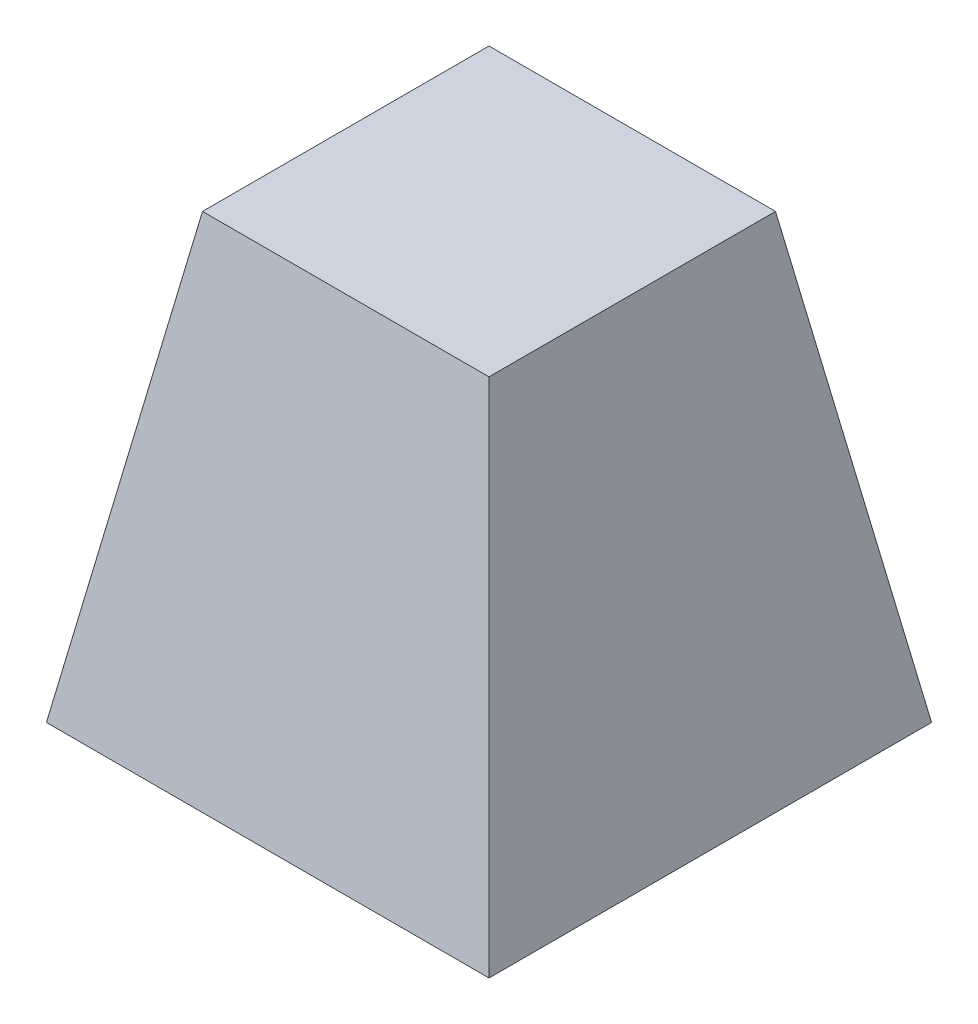
from build123d import *

# Parameters (mm, degrees)
SKETCH1_W           = 25.4
SKETCH1_H           = 25.4
BOSS_EXTRUDE1_DEPTH = 25.4
BOSS_EXTRUDE1_TAPER = 10


with BuildPart() as part:
    # Sketch1 → Boss-Extrude1 (new body)
    with BuildSketch(Plane(origin=(0, 0, 0), x_dir=(1, 0, 0), z_dir=(0, 1, 0))):
        Rectangle(SKETCH1_W, SKETCH1_H)
    extrude(amount=BOSS_EXTRUDE1_DEPTH, taper=BOSS_EXTRUDE1_TAPER)


solid = part.part
